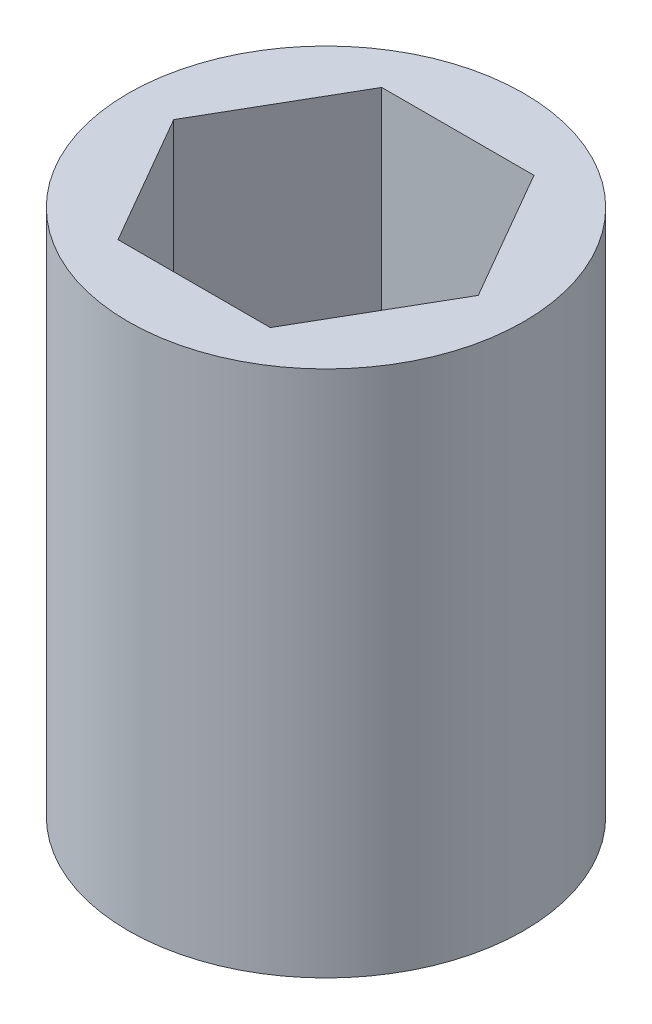
from build123d import *

# Parameters (mm, degrees)
SKETCH1_R           = 9.525
BOSS_EXTRUDE1_DEPTH = 25.4


with BuildPart() as part:
    # Sketch1 → Boss-Extrude1 (new body)
    with BuildSketch(Plane(origin=(0, 0, 0), x_dir=(1, 0, 0), z_dir=(0, 1, 0))):
        Circle(SKETCH1_R)
        Polygon((7.332348419, 0), (3.666174209, 6.35), (-3.666174209, 6.35), (-7.332348419, 0), (-3.666174209, -6.35), (3.666174209, -6.35), align=None, mode=Mode.SUBTRACT)
    extrude(amount=BOSS_EXTRUDE1_DEPTH)


solid = part.part
